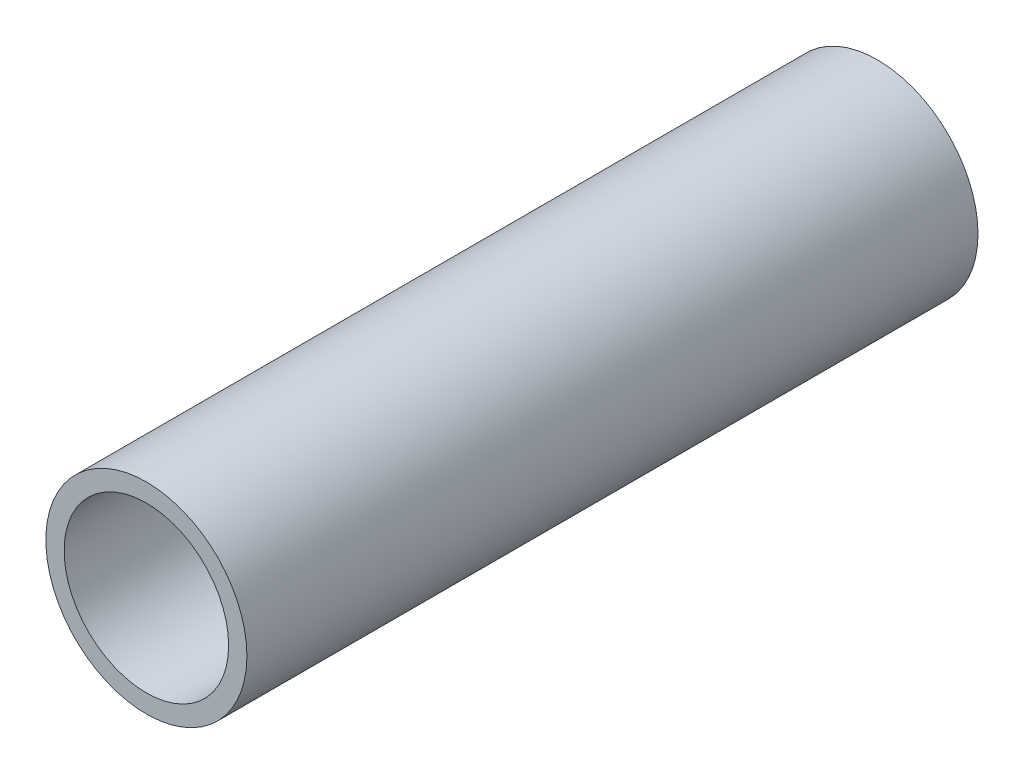
from build123d import *

# Parameters (mm, degrees)
SKETCH1_W = 80
SKETCH1_H = 2


with BuildPart() as part:
    # Sketch1 → Revolve1 (revolve)
    with BuildSketch(Plane(origin=(0, 0, 0), x_dir=(0, 0, -1), z_dir=(1, 0, 0))):
        with Locations((0, 10)):
            Rectangle(SKETCH1_W, SKETCH1_H)
    revolve(axis=Axis((0, 0, 0), (0, 0, -1)))


solid = part.part
